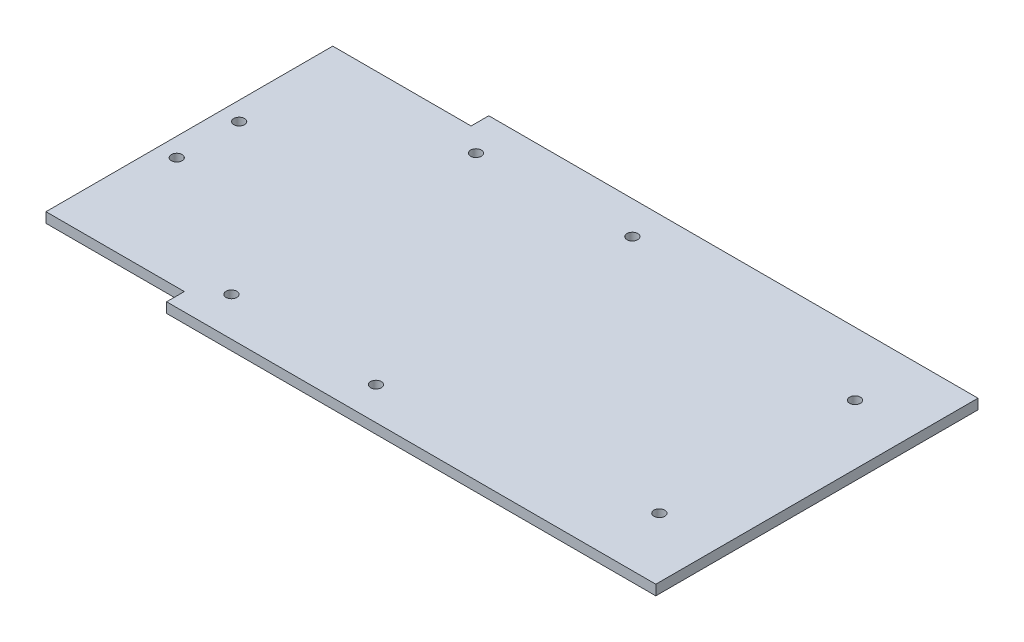
from build123d import *

# Parameters (mm, degrees)
BOSS_EXTRUDE1_DEPTH = 3
SKETCH2_R           = 1.6
CUT_EXTRUDE1_DEPTH  = 4


with BuildPart() as part:
    # Sketch1 → Boss-Extrude1 (new body)
    with BuildSketch(Plane(origin=(0, 0, 0), x_dir=(1, 0, 0), z_dir=(0, 1, 0))):
        Polygon((41, 5.25), (41, 0), (186, 0), (186, 95.5), (41, 95.5), (41, 90.25), (0, 90.25), (0, 5.25), align=None)
    extrude(amount=BOSS_EXTRUDE1_DEPTH)

    # Sketch2 → Cut-Extrude1 (cut, through all)
    with BuildSketch(Plane(origin=(0, 3, 0), x_dir=(1, 0, 0), z_dir=(0, 1, 0))):
        with Locations((5.5, 38.5)):
            Circle(SKETCH2_R)
        with Locations((5.5, 57)):
            Circle(SKETCH2_R)
        with Locations((48.7, 11.5)):
            Circle(SKETCH2_R)
        with Locations((93.3, 9.75)):
            Circle(SKETCH2_R)
        with Locations((168.3, 18.75)):
            Circle(SKETCH2_R)
        with Locations((168.3, 76.75)):
            Circle(SKETCH2_R)
        with Locations((93.3, 85.75)):
            Circle(SKETCH2_R)
        with Locations((48.7, 84)):
            Circle(SKETCH2_R)
    extrude(amount=-CUT_EXTRUDE1_DEPTH, mode=Mode.SUBTRACT)


solid = part.part
